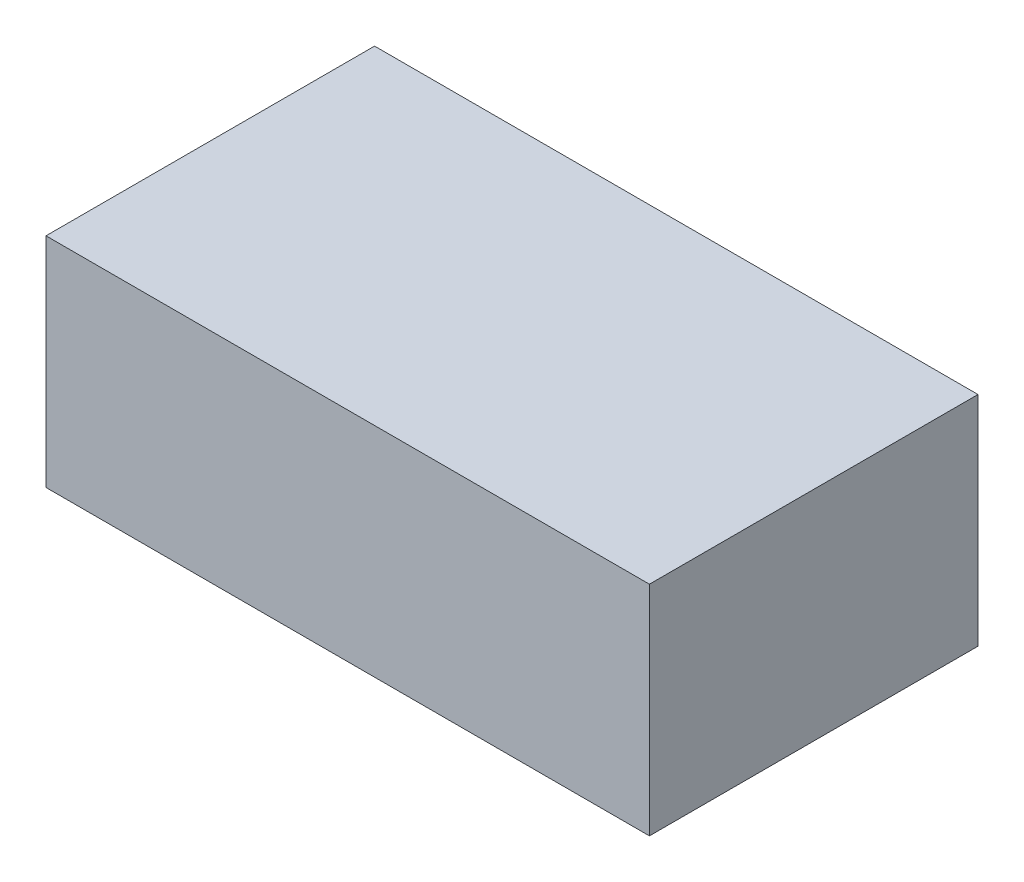
from build123d import *

# Parameters (mm, degrees)
SKETCH2_W           = 48.514
SKETCH2_H           = 26.416
BOSS_EXTRUDE1_DEPTH = 17.526


with BuildPart() as part:
    # Sketch2 → Boss-Extrude1 (new body)
    with BuildSketch(Plane(origin=(0, 0, 0), x_dir=(1, 0, 0), z_dir=(0, 1, 0))):
        Rectangle(SKETCH2_W, SKETCH2_H)
    extrude(amount=BOSS_EXTRUDE1_DEPTH)


solid = part.part
